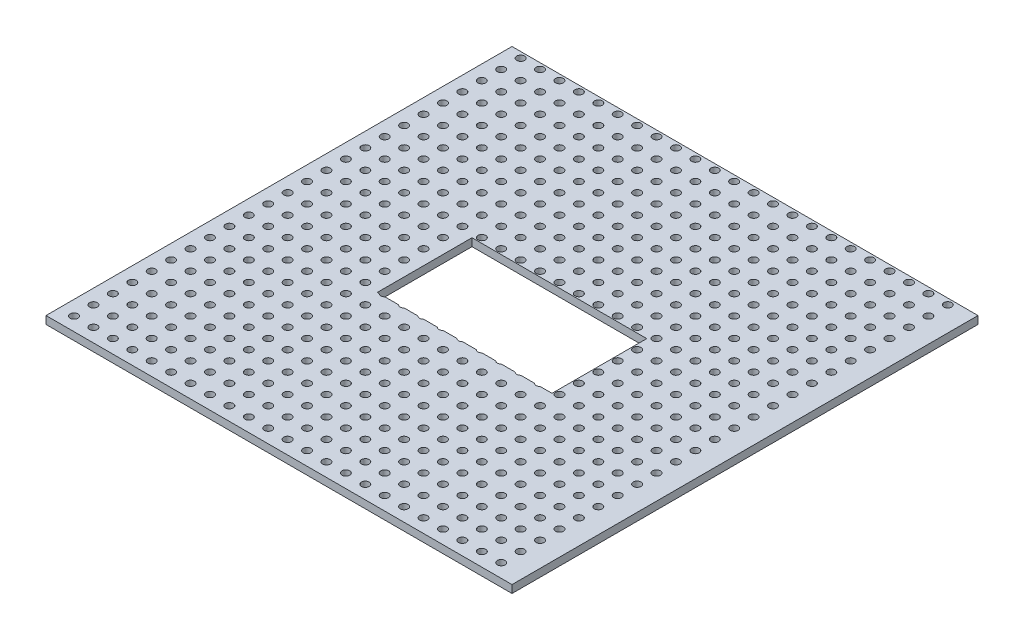
from build123d import *

# Parameters (mm, degrees)
SKETCH1_W           = 60
SKETCH1_H           = 60
SKETCH1_W_2         = 22.5
SKETCH1_H_2         = 12.2
BOSS_EXTRUDE1_DEPTH = 1
SKETCH2_R           = 0.5
CUT_EXTRUDE1_DEPTH  = 2


with BuildPart() as part:
    # Sketch1 → Boss-Extrude1 (new body)
    with BuildSketch(Plane(origin=(0, 0, 0), x_dir=(1, 0, 0), z_dir=(0, 1, 0))):
        with Locations((-12.648237996, 30)):
            Rectangle(SKETCH1_W, SKETCH1_H)
        with Locations((-12.648237996, 30)):
            Rectangle(SKETCH1_W_2, SKETCH1_H_2, mode=Mode.SUBTRACT)
    extrude(amount=BOSS_EXTRUDE1_DEPTH)

    # Sketch2 → Cut-Extrude1 (cut, through all)
    with BuildSketch(Plane(origin=(0, 1, 0), x_dir=(1, 0, 0), z_dir=(0, 1, 0))):
        with Locations((14.218009326, 59.244517789)):
            Circle(SKETCH2_R)
        with Locations((11.718009326, 59.244517789)):
            Circle(SKETCH2_R)
        with Locations((9.218009326, 59.244517789)):
            Circle(SKETCH2_R)
        with Locations((6.718009326, 59.244517789)):
            Circle(SKETCH2_R)
        with Locations((4.218009326, 59.244517789)):
            Circle(SKETCH2_R)
        with Locations((1.718009326, 59.244517789)):
            Circle(SKETCH2_R)
        with Locations((-0.781990674, 59.244517789)):
            Circle(SKETCH2_R)
        with Locations((-3.281990674, 59.244517789)):
            Circle(SKETCH2_R)
        with Locations((-5.781990674, 59.244517789)):
            Circle(SKETCH2_R)
        with Locations((-8.281990674, 59.244517789)):
            Circle(SKETCH2_R)
        with Locations((-10.781990674, 59.244517789)):
            Circle(SKETCH2_R)
        with Locations((-13.281990674, 59.244517789)):
            Circle(SKETCH2_R)
        with Locations((-15.781990674, 59.244517789)):
            Circle(SKETCH2_R)
        with Locations((-18.281990674, 59.244517789)):
            Circle(SKETCH2_R)
        with Locations((-20.781990674, 59.244517789)):
            Circle(SKETCH2_R)
        with Locations((-23.281990674, 59.244517789)):
            Circle(SKETCH2_R)
        with Locations((-25.781990674, 59.244517789)):
            Circle(SKETCH2_R)
        with Locations((-28.281990674, 59.244517789)):
            Circle(SKETCH2_R)
        with Locations((-30.781990674, 59.244517789)):
            Circle(SKETCH2_R)
        with Locations((-33.281990674, 59.244517789)):
            Circle(SKETCH2_R)
        with Locations((-35.781990674, 59.244517789)):
            Circle(SKETCH2_R)
        with Locations((-38.281990674, 59.244517789)):
            Circle(SKETCH2_R)
        with Locations((-40.781990674, 59.244517789)):
            Circle(SKETCH2_R)
        with Locations((-43.281990674, 59.244517789)):
            Circle(SKETCH2_R)
        with Locations((11.718009326, 56.744517789)):
            Circle(SKETCH2_R)
        with Locations((9.218009326, 56.744517789)):
            Circle(SKETCH2_R)
        with Locations((6.718009326, 56.744517789)):
            Circle(SKETCH2_R)
        with Locations((4.218009326, 56.744517789)):
            Circle(SKETCH2_R)
        with Locations((1.718009326, 56.744517789)):
            Circle(SKETCH2_R)
        with Locations((-0.781990674, 56.744517789)):
            Circle(SKETCH2_R)
        with Locations((-3.281990674, 56.744517789)):
            Circle(SKETCH2_R)
        with Locations((-5.781990674, 56.744517789)):
            Circle(SKETCH2_R)
        with Locations((-8.281990674, 56.744517789)):
            Circle(SKETCH2_R)
        with Locations((-10.781990674, 56.744517789)):
            Circle(SKETCH2_R)
        with Locations((-13.281990674, 56.744517789)):
            Circle(SKETCH2_R)
        with Locations((-15.781990674, 56.744517789)):
            Circle(SKETCH2_R)
        with Locations((-18.281990674, 56.744517789)):
            Circle(SKETCH2_R)
        with Locations((-20.781990674, 56.744517789)):
            Circle(SKETCH2_R)
        with Locations((-23.281990674, 56.744517789)):
            Circle(SKETCH2_R)
        with Locations((-25.781990674, 56.744517789)):
            Circle(SKETCH2_R)
        with Locations((-28.281990674, 56.744517789)):
            Circle(SKETCH2_R)
        with Locations((-30.781990674, 56.744517789)):
            Circle(SKETCH2_R)
        with Locations((-33.281990674, 56.744517789)):
            Circle(SKETCH2_R)
        with Locations((-35.781990674, 56.744517789)):
            Circle(SKETCH2_R)
        with Locations((-38.281990674, 56.744517789)):
            Circle(SKETCH2_R)
        with Locations((-40.781990674, 56.744517789)):
            Circle(SKETCH2_R)
        with Locations((-43.281990674, 56.744517789)):
            Circle(SKETCH2_R)
        with Locations((11.718009326, 54.244517789)):
            Circle(SKETCH2_R)
        with Locations((9.218009326, 54.244517789)):
            Circle(SKETCH2_R)
        with Locations((6.718009326, 54.244517789)):
            Circle(SKETCH2_R)
        with Locations((4.218009326, 54.244517789)):
            Circle(SKETCH2_R)
        with Locations((1.718009326, 54.244517789)):
            Circle(SKETCH2_R)
        with Locations((-0.781990674, 54.244517789)):
            Circle(SKETCH2_R)
        with Locations((-3.281990674, 54.244517789)):
            Circle(SKETCH2_R)
        with Locations((-5.781990674, 54.244517789)):
            Circle(SKETCH2_R)
        with Locations((-8.281990674, 54.244517789)):
            Circle(SKETCH2_R)
        with Locations((-10.781990674, 54.244517789)):
            Circle(SKETCH2_R)
        with Locations((-13.281990674, 54.244517789)):
            Circle(SKETCH2_R)
        with Locations((-15.781990674, 54.244517789)):
            Circle(SKETCH2_R)
        with Locations((-18.281990674, 54.244517789)):
            Circle(SKETCH2_R)
        with Locations((-20.781990674, 54.244517789)):
            Circle(SKETCH2_R)
        with Locations((-23.281990674, 54.244517789)):
            Circle(SKETCH2_R)
        with Locations((-25.781990674, 54.244517789)):
            Circle(SKETCH2_R)
        with Locations((-28.281990674, 54.244517789)):
            Circle(SKETCH2_R)
        with Locations((-30.781990674, 54.244517789)):
            Circle(SKETCH2_R)
        with Locations((-33.281990674, 54.244517789)):
            Circle(SKETCH2_R)
        with Locations((-35.781990674, 54.244517789)):
            Circle(SKETCH2_R)
        with Locations((-38.281990674, 54.244517789)):
            Circle(SKETCH2_R)
        with Locations((-40.781990674, 54.244517789)):
            Circle(SKETCH2_R)
        with Locations((-43.281990674, 54.244517789)):
            Circle(SKETCH2_R)
        with Locations((11.718009326, 51.744517789)):
            Circle(SKETCH2_R)
        with Locations((9.218009326, 51.744517789)):
            Circle(SKETCH2_R)
        with Locations((6.718009326, 51.744517789)):
            Circle(SKETCH2_R)
        with Locations((4.218009326, 51.744517789)):
            Circle(SKETCH2_R)
        with Locations((1.718009326, 51.744517789)):
            Circle(SKETCH2_R)
        with Locations((-0.781990674, 51.744517789)):
            Circle(SKETCH2_R)
        with Locations((-3.281990674, 51.744517789)):
            Circle(SKETCH2_R)
        with Locations((-5.781990674, 51.744517789)):
            Circle(SKETCH2_R)
        with Locations((-8.281990674, 51.744517789)):
            Circle(SKETCH2_R)
        with Locations((-10.781990674, 51.744517789)):
            Circle(SKETCH2_R)
        with Locations((-13.281990674, 51.744517789)):
            Circle(SKETCH2_R)
        with Locations((-15.781990674, 51.744517789)):
            Circle(SKETCH2_R)
        with Locations((-18.281990674, 51.744517789)):
            Circle(SKETCH2_R)
        with Locations((-20.781990674, 51.744517789)):
            Circle(SKETCH2_R)
        with Locations((-23.281990674, 51.744517789)):
            Circle(SKETCH2_R)
        with Locations((-25.781990674, 51.744517789)):
            Circle(SKETCH2_R)
        with Locations((-28.281990674, 51.744517789)):
            Circle(SKETCH2_R)
        with Locations((-30.781990674, 51.744517789)):
            Circle(SKETCH2_R)
        with Locations((-33.281990674, 51.744517789)):
            Circle(SKETCH2_R)
        with Locations((-35.781990674, 51.744517789)):
            Circle(SKETCH2_R)
        with Locations((-38.281990674, 51.744517789)):
            Circle(SKETCH2_R)
        with Locations((-40.781990674, 51.744517789)):
            Circle(SKETCH2_R)
        with Locations((-43.281990674, 51.744517789)):
            Circle(SKETCH2_R)
        with Locations((11.718009326, 49.244517789)):
            Circle(SKETCH2_R)
        with Locations((9.218009326, 49.244517789)):
            Circle(SKETCH2_R)
        with Locations((6.718009326, 49.244517789)):
            Circle(SKETCH2_R)
        with Locations((4.218009326, 49.244517789)):
            Circle(SKETCH2_R)
        with Locations((1.718009326, 49.244517789)):
            Circle(SKETCH2_R)
        with Locations((-0.781990674, 49.244517789)):
            Circle(SKETCH2_R)
        with Locations((-3.281990674, 49.244517789)):
            Circle(SKETCH2_R)
        with Locations((-5.781990674, 49.244517789)):
            Circle(SKETCH2_R)
        with Locations((-8.281990674, 49.244517789)):
            Circle(SKETCH2_R)
        with Locations((-10.781990674, 49.244517789)):
            Circle(SKETCH2_R)
        with Locations((-13.281990674, 49.244517789)):
            Circle(SKETCH2_R)
        with Locations((-15.781990674, 49.244517789)):
            Circle(SKETCH2_R)
        with Locations((-18.281990674, 49.244517789)):
            Circle(SKETCH2_R)
        with Locations((-20.781990674, 49.244517789)):
            Circle(SKETCH2_R)
        with Locations((-23.281990674, 49.244517789)):
            Circle(SKETCH2_R)
        with Locations((-25.781990674, 49.244517789)):
            Circle(SKETCH2_R)
        with Locations((-28.281990674, 49.244517789)):
            Circle(SKETCH2_R)
        with Locations((-30.781990674, 49.244517789)):
            Circle(SKETCH2_R)
        with Locations((-33.281990674, 49.244517789)):
            Circle(SKETCH2_R)
        with Locations((-35.781990674, 49.244517789)):
            Circle(SKETCH2_R)
        with Locations((-38.281990674, 49.244517789)):
            Circle(SKETCH2_R)
        with Locations((-40.781990674, 49.244517789)):
            Circle(SKETCH2_R)
        with Locations((-43.281990674, 49.244517789)):
            Circle(SKETCH2_R)
        with Locations((11.718009326, 46.744517789)):
            Circle(SKETCH2_R)
        with Locations((9.218009326, 46.744517789)):
            Circle(SKETCH2_R)
        with Locations((6.718009326, 46.744517789)):
            Circle(SKETCH2_R)
        with Locations((4.218009326, 46.744517789)):
            Circle(SKETCH2_R)
        with Locations((1.718009326, 46.744517789)):
            Circle(SKETCH2_R)
        with Locations((-0.781990674, 46.744517789)):
            Circle(SKETCH2_R)
        with Locations((-3.281990674, 46.744517789)):
            Circle(SKETCH2_R)
        with Locations((-5.781990674, 46.744517789)):
            Circle(SKETCH2_R)
        with Locations((-8.281990674, 46.744517789)):
            Circle(SKETCH2_R)
        with Locations((-10.781990674, 46.744517789)):
            Circle(SKETCH2_R)
        with Locations((-13.281990674, 46.744517789)):
            Circle(SKETCH2_R)
        with Locations((-15.781990674, 46.744517789)):
            Circle(SKETCH2_R)
        with Locations((-18.281990674, 46.744517789)):
            Circle(SKETCH2_R)
        with Locations((-20.781990674, 46.744517789)):
            Circle(SKETCH2_R)
        with Locations((-23.281990674, 46.744517789)):
            Circle(SKETCH2_R)
        with Locations((-25.781990674, 46.744517789)):
            Circle(SKETCH2_R)
        with Locations((-28.281990674, 46.744517789)):
            Circle(SKETCH2_R)
        with Locations((-30.781990674, 46.744517789)):
            Circle(SKETCH2_R)
        with Locations((-33.281990674, 46.744517789)):
            Circle(SKETCH2_R)
        with Locations((-35.781990674, 46.744517789)):
            Circle(SKETCH2_R)
        with Locations((-38.281990674, 46.744517789)):
            Circle(SKETCH2_R)
        with Locations((-40.781990674, 46.744517789)):
            Circle(SKETCH2_R)
        with Locations((-43.281990674, 46.744517789)):
            Circle(SKETCH2_R)
        with Locations((11.718009326, 44.244517789)):
            Circle(SKETCH2_R)
        with Locations((9.218009326, 44.244517789)):
            Circle(SKETCH2_R)
        with Locations((6.718009326, 44.244517789)):
            Circle(SKETCH2_R)
        with Locations((4.218009326, 44.244517789)):
            Circle(SKETCH2_R)
        with Locations((1.718009326, 44.244517789)):
            Circle(SKETCH2_R)
        with Locations((-0.781990674, 44.244517789)):
            Circle(SKETCH2_R)
        with Locations((-3.281990674, 44.244517789)):
            Circle(SKETCH2_R)
        with Locations((-5.781990674, 44.244517789)):
            Circle(SKETCH2_R)
        with Locations((-8.281990674, 44.244517789)):
            Circle(SKETCH2_R)
        with Locations((-10.781990674, 44.244517789)):
            Circle(SKETCH2_R)
        with Locations((-13.281990674, 44.244517789)):
            Circle(SKETCH2_R)
        with Locations((-15.781990674, 44.244517789)):
            Circle(SKETCH2_R)
        with Locations((-18.281990674, 44.244517789)):
            Circle(SKETCH2_R)
        with Locations((-20.781990674, 44.244517789)):
            Circle(SKETCH2_R)
        with Locations((-23.281990674, 44.244517789)):
            Circle(SKETCH2_R)
        with Locations((-25.781990674, 44.244517789)):
            Circle(SKETCH2_R)
        with Locations((-28.281990674, 44.244517789)):
            Circle(SKETCH2_R)
        with Locations((-30.781990674, 44.244517789)):
            Circle(SKETCH2_R)
        with Locations((-33.281990674, 44.244517789)):
            Circle(SKETCH2_R)
        with Locations((-35.781990674, 44.244517789)):
            Circle(SKETCH2_R)
        with Locations((-38.281990674, 44.244517789)):
            Circle(SKETCH2_R)
        with Locations((-40.781990674, 44.244517789)):
            Circle(SKETCH2_R)
        with Locations((-43.281990674, 44.244517789)):
            Circle(SKETCH2_R)
        with Locations((11.718009326, 41.744517789)):
            Circle(SKETCH2_R)
        with Locations((9.218009326, 41.744517789)):
            Circle(SKETCH2_R)
        with Locations((6.718009326, 41.744517789)):
            Circle(SKETCH2_R)
        with Locations((4.218009326, 41.744517789)):
            Circle(SKETCH2_R)
        with Locations((1.718009326, 41.744517789)):
            Circle(SKETCH2_R)
        with Locations((-0.781990674, 41.744517789)):
            Circle(SKETCH2_R)
        with Locations((-3.281990674, 41.744517789)):
            Circle(SKETCH2_R)
        with Locations((-5.781990674, 41.744517789)):
            Circle(SKETCH2_R)
        with Locations((-8.281990674, 41.744517789)):
            Circle(SKETCH2_R)
        with Locations((-10.781990674, 41.744517789)):
            Circle(SKETCH2_R)
        with Locations((-13.281990674, 41.744517789)):
            Circle(SKETCH2_R)
        with Locations((-15.781990674, 41.744517789)):
            Circle(SKETCH2_R)
        with Locations((-18.281990674, 41.744517789)):
            Circle(SKETCH2_R)
        with Locations((-20.781990674, 41.744517789)):
            Circle(SKETCH2_R)
        with Locations((-23.281990674, 41.744517789)):
            Circle(SKETCH2_R)
        with Locations((-25.781990674, 41.744517789)):
            Circle(SKETCH2_R)
        with Locations((-28.281990674, 41.744517789)):
            Circle(SKETCH2_R)
        with Locations((-30.781990674, 41.744517789)):
            Circle(SKETCH2_R)
        with Locations((-33.281990674, 41.744517789)):
            Circle(SKETCH2_R)
        with Locations((-35.781990674, 41.744517789)):
            Circle(SKETCH2_R)
        with Locations((-38.281990674, 41.744517789)):
            Circle(SKETCH2_R)
        with Locations((-40.781990674, 41.744517789)):
            Circle(SKETCH2_R)
        with Locations((-43.281990674, 41.744517789)):
            Circle(SKETCH2_R)
        with Locations((11.718009326, 39.244517789)):
            Circle(SKETCH2_R)
        with Locations((9.218009326, 39.244517789)):
            Circle(SKETCH2_R)
        with Locations((6.718009326, 39.244517789)):
            Circle(SKETCH2_R)
        with Locations((4.218009326, 39.244517789)):
            Circle(SKETCH2_R)
        with Locations((1.718009326, 39.244517789)):
            Circle(SKETCH2_R)
        with Locations((-0.781990674, 39.244517789)):
            Circle(SKETCH2_R)
        with Locations((-3.281990674, 39.244517789)):
            Circle(SKETCH2_R)
        with Locations((-5.781990674, 39.244517789)):
            Circle(SKETCH2_R)
        with Locations((-8.281990674, 39.244517789)):
            Circle(SKETCH2_R)
        with Locations((-10.781990674, 39.244517789)):
            Circle(SKETCH2_R)
        with Locations((-13.281990674, 39.244517789)):
            Circle(SKETCH2_R)
        with Locations((-15.781990674, 39.244517789)):
            Circle(SKETCH2_R)
        with Locations((-18.281990674, 39.244517789)):
            Circle(SKETCH2_R)
        with Locations((-20.781990674, 39.244517789)):
            Circle(SKETCH2_R)
        with Locations((-23.281990674, 39.244517789)):
            Circle(SKETCH2_R)
        with Locations((-25.781990674, 39.244517789)):
            Circle(SKETCH2_R)
        with Locations((-28.281990674, 39.244517789)):
            Circle(SKETCH2_R)
        with Locations((-30.781990674, 39.244517789)):
            Circle(SKETCH2_R)
        with Locations((-33.281990674, 39.244517789)):
            Circle(SKETCH2_R)
        with Locations((-35.781990674, 39.244517789)):
            Circle(SKETCH2_R)
        with Locations((-38.281990674, 39.244517789)):
            Circle(SKETCH2_R)
        with Locations((-40.781990674, 39.244517789)):
            Circle(SKETCH2_R)
        with Locations((-43.281990674, 39.244517789)):
            Circle(SKETCH2_R)
        with Locations((11.718009326, 36.744517789)):
            Circle(SKETCH2_R)
        with Locations((9.218009326, 36.744517789)):
            Circle(SKETCH2_R)
        with Locations((6.718009326, 36.744517789)):
            Circle(SKETCH2_R)
        with Locations((4.218009326, 36.744517789)):
            Circle(SKETCH2_R)
        with Locations((1.718009326, 36.744517789)):
            Circle(SKETCH2_R)
        with Locations((-0.781990674, 36.744517789)):
            Circle(SKETCH2_R)
        with Locations((-3.281990674, 36.744517789)):
            Circle(SKETCH2_R)
        with Locations((-5.781990674, 36.744517789)):
            Circle(SKETCH2_R)
        with Locations((-8.281990674, 36.744517789)):
            Circle(SKETCH2_R)
        with Locations((-10.781990674, 36.744517789)):
            Circle(SKETCH2_R)
        with Locations((-13.281990674, 36.744517789)):
            Circle(SKETCH2_R)
        with Locations((-15.781990674, 36.744517789)):
            Circle(SKETCH2_R)
        with Locations((-18.281990674, 36.744517789)):
            Circle(SKETCH2_R)
        with Locations((-20.781990674, 36.744517789)):
            Circle(SKETCH2_R)
        with Locations((-23.281990674, 36.744517789)):
            Circle(SKETCH2_R)
        with Locations((-25.781990674, 36.744517789)):
            Circle(SKETCH2_R)
        with Locations((-28.281990674, 36.744517789)):
            Circle(SKETCH2_R)
        with Locations((-30.781990674, 36.744517789)):
            Circle(SKETCH2_R)
        with Locations((-33.281990674, 36.744517789)):
            Circle(SKETCH2_R)
        with Locations((-35.781990674, 36.744517789)):
            Circle(SKETCH2_R)
        with Locations((-38.281990674, 36.744517789)):
            Circle(SKETCH2_R)
        with Locations((-40.781990674, 36.744517789)):
            Circle(SKETCH2_R)
        with Locations((-43.281990674, 36.744517789)):
            Circle(SKETCH2_R)
        with Locations((11.718009326, 34.244517789)):
            Circle(SKETCH2_R)
        with Locations((9.218009326, 34.244517789)):
            Circle(SKETCH2_R)
        with Locations((6.718009326, 34.244517789)):
            Circle(SKETCH2_R)
        with Locations((4.218009326, 34.244517789)):
            Circle(SKETCH2_R)
        with Locations((1.718009326, 34.244517789)):
            Circle(SKETCH2_R)
        with Locations((-0.781990674, 34.244517789)):
            Circle(SKETCH2_R)
        with Locations((-3.281990674, 34.244517789)):
            Circle(SKETCH2_R)
        with Locations((-5.781990674, 34.244517789)):
            Circle(SKETCH2_R)
        with Locations((-8.281990674, 34.244517789)):
            Circle(SKETCH2_R)
        with Locations((-10.781990674, 34.244517789)):
            Circle(SKETCH2_R)
        with Locations((-13.281990674, 34.244517789)):
            Circle(SKETCH2_R)
        with Locations((-15.781990674, 34.244517789)):
            Circle(SKETCH2_R)
        with Locations((-18.281990674, 34.244517789)):
            Circle(SKETCH2_R)
        with Locations((-20.781990674, 34.244517789)):
            Circle(SKETCH2_R)
        with Locations((-23.281990674, 34.244517789)):
            Circle(SKETCH2_R)
        with Locations((-25.781990674, 34.244517789)):
            Circle(SKETCH2_R)
        with Locations((-28.281990674, 34.244517789)):
            Circle(SKETCH2_R)
        with Locations((-30.781990674, 34.244517789)):
            Circle(SKETCH2_R)
        with Locations((-33.281990674, 34.244517789)):
            Circle(SKETCH2_R)
        with Locations((-35.781990674, 34.244517789)):
            Circle(SKETCH2_R)
        with Locations((-38.281990674, 34.244517789)):
            Circle(SKETCH2_R)
        with Locations((-40.781990674, 34.244517789)):
            Circle(SKETCH2_R)
        with Locations((-43.281990674, 34.244517789)):
            Circle(SKETCH2_R)
        with Locations((11.718009326, 31.744517789)):
            Circle(SKETCH2_R)
        with Locations((9.218009326, 31.744517789)):
            Circle(SKETCH2_R)
        with Locations((6.718009326, 31.744517789)):
            Circle(SKETCH2_R)
        with Locations((4.218009326, 31.744517789)):
            Circle(SKETCH2_R)
        with Locations((1.718009326, 31.744517789)):
            Circle(SKETCH2_R)
        with Locations((-0.781990674, 31.744517789)):
            Circle(SKETCH2_R)
        with Locations((-3.281990674, 31.744517789)):
            Circle(SKETCH2_R)
        with Locations((-5.781990674, 31.744517789)):
            Circle(SKETCH2_R)
        with Locations((-8.281990674, 31.744517789)):
            Circle(SKETCH2_R)
        with Locations((-10.781990674, 31.744517789)):
            Circle(SKETCH2_R)
        with Locations((-13.281990674, 31.744517789)):
            Circle(SKETCH2_R)
        with Locations((-15.781990674, 31.744517789)):
            Circle(SKETCH2_R)
        with Locations((-18.281990674, 31.744517789)):
            Circle(SKETCH2_R)
        with Locations((-20.781990674, 31.744517789)):
            Circle(SKETCH2_R)
        with Locations((-23.281990674, 31.744517789)):
            Circle(SKETCH2_R)
        with Locations((-25.781990674, 31.744517789)):
            Circle(SKETCH2_R)
        with Locations((-28.281990674, 31.744517789)):
            Circle(SKETCH2_R)
        with Locations((-30.781990674, 31.744517789)):
            Circle(SKETCH2_R)
        with Locations((-33.281990674, 31.744517789)):
            Circle(SKETCH2_R)
        with Locations((-35.781990674, 31.744517789)):
            Circle(SKETCH2_R)
        with Locations((-38.281990674, 31.744517789)):
            Circle(SKETCH2_R)
        with Locations((-40.781990674, 31.744517789)):
            Circle(SKETCH2_R)
        with Locations((-43.281990674, 31.744517789)):
            Circle(SKETCH2_R)
        with Locations((11.718009326, 29.244517789)):
            Circle(SKETCH2_R)
        with Locations((9.218009326, 29.244517789)):
            Circle(SKETCH2_R)
        with Locations((6.718009326, 29.244517789)):
            Circle(SKETCH2_R)
        with Locations((4.218009326, 29.244517789)):
            Circle(SKETCH2_R)
        with Locations((1.718009326, 29.244517789)):
            Circle(SKETCH2_R)
        with Locations((-0.781990674, 29.244517789)):
            Circle(SKETCH2_R)
        with Locations((-3.281990674, 29.244517789)):
            Circle(SKETCH2_R)
        with Locations((-5.781990674, 29.244517789)):
            Circle(SKETCH2_R)
        with Locations((-8.281990674, 29.244517789)):
            Circle(SKETCH2_R)
        with Locations((-10.781990674, 29.244517789)):
            Circle(SKETCH2_R)
        with Locations((-13.281990674, 29.244517789)):
            Circle(SKETCH2_R)
        with Locations((-15.781990674, 29.244517789)):
            Circle(SKETCH2_R)
        with Locations((-18.281990674, 29.244517789)):
            Circle(SKETCH2_R)
        with Locations((-20.781990674, 29.244517789)):
            Circle(SKETCH2_R)
        with Locations((-23.281990674, 29.244517789)):
            Circle(SKETCH2_R)
        with Locations((-25.781990674, 29.244517789)):
            Circle(SKETCH2_R)
        with Locations((-28.281990674, 29.244517789)):
            Circle(SKETCH2_R)
        with Locations((-30.781990674, 29.244517789)):
            Circle(SKETCH2_R)
        with Locations((-33.281990674, 29.244517789)):
            Circle(SKETCH2_R)
        with Locations((-35.781990674, 29.244517789)):
            Circle(SKETCH2_R)
        with Locations((-38.281990674, 29.244517789)):
            Circle(SKETCH2_R)
        with Locations((-40.781990674, 29.244517789)):
            Circle(SKETCH2_R)
        with Locations((-43.281990674, 29.244517789)):
            Circle(SKETCH2_R)
        with Locations((11.718009326, 26.744517789)):
            Circle(SKETCH2_R)
        with Locations((9.218009326, 26.744517789)):
            Circle(SKETCH2_R)
        with Locations((6.718009326, 26.744517789)):
            Circle(SKETCH2_R)
        with Locations((4.218009326, 26.744517789)):
            Circle(SKETCH2_R)
        with Locations((1.718009326, 26.744517789)):
            Circle(SKETCH2_R)
        with Locations((-0.781990674, 26.744517789)):
            Circle(SKETCH2_R)
        with Locations((-3.281990674, 26.744517789)):
            Circle(SKETCH2_R)
        with Locations((-5.781990674, 26.744517789)):
            Circle(SKETCH2_R)
        with Locations((-8.281990674, 26.744517789)):
            Circle(SKETCH2_R)
        with Locations((-10.781990674, 26.744517789)):
            Circle(SKETCH2_R)
        with Locations((-13.281990674, 26.744517789)):
            Circle(SKETCH2_R)
        with Locations((-15.781990674, 26.744517789)):
            Circle(SKETCH2_R)
        with Locations((-18.281990674, 26.744517789)):
            Circle(SKETCH2_R)
        with Locations((-20.781990674, 26.744517789)):
            Circle(SKETCH2_R)
        with Locations((-23.281990674, 26.744517789)):
            Circle(SKETCH2_R)
        with Locations((-25.781990674, 26.744517789)):
            Circle(SKETCH2_R)
        with Locations((-28.281990674, 26.744517789)):
            Circle(SKETCH2_R)
        with Locations((-30.781990674, 26.744517789)):
            Circle(SKETCH2_R)
        with Locations((-33.281990674, 26.744517789)):
            Circle(SKETCH2_R)
        with Locations((-35.781990674, 26.744517789)):
            Circle(SKETCH2_R)
        with Locations((-38.281990674, 26.744517789)):
            Circle(SKETCH2_R)
        with Locations((-40.781990674, 26.744517789)):
            Circle(SKETCH2_R)
        with Locations((-43.281990674, 26.744517789)):
            Circle(SKETCH2_R)
        with Locations((11.718009326, 24.244517789)):
            Circle(SKETCH2_R)
        with Locations((9.218009326, 24.244517789)):
            Circle(SKETCH2_R)
        with Locations((6.718009326, 24.244517789)):
            Circle(SKETCH2_R)
        with Locations((4.218009326, 24.244517789)):
            Circle(SKETCH2_R)
        with Locations((1.718009326, 24.244517789)):
            Circle(SKETCH2_R)
        with Locations((-0.781990674, 24.244517789)):
            Circle(SKETCH2_R)
        with Locations((-3.281990674, 24.244517789)):
            Circle(SKETCH2_R)
        with Locations((-5.781990674, 24.244517789)):
            Circle(SKETCH2_R)
        with Locations((-8.281990674, 24.244517789)):
            Circle(SKETCH2_R)
        with Locations((-10.781990674, 24.244517789)):
            Circle(SKETCH2_R)
        with Locations((-13.281990674, 24.244517789)):
            Circle(SKETCH2_R)
        with Locations((-15.781990674, 24.244517789)):
            Circle(SKETCH2_R)
        with Locations((-18.281990674, 24.244517789)):
            Circle(SKETCH2_R)
        with Locations((-20.781990674, 24.244517789)):
            Circle(SKETCH2_R)
        with Locations((-23.281990674, 24.244517789)):
            Circle(SKETCH2_R)
        with Locations((-25.781990674, 24.244517789)):
            Circle(SKETCH2_R)
        with Locations((-28.281990674, 24.244517789)):
            Circle(SKETCH2_R)
        with Locations((-30.781990674, 24.244517789)):
            Circle(SKETCH2_R)
        with Locations((-33.281990674, 24.244517789)):
            Circle(SKETCH2_R)
        with Locations((-35.781990674, 24.244517789)):
            Circle(SKETCH2_R)
        with Locations((-38.281990674, 24.244517789)):
            Circle(SKETCH2_R)
        with Locations((-40.781990674, 24.244517789)):
            Circle(SKETCH2_R)
        with Locations((-43.281990674, 24.244517789)):
            Circle(SKETCH2_R)
        with Locations((11.718009326, 21.744517789)):
            Circle(SKETCH2_R)
        with Locations((9.218009326, 21.744517789)):
            Circle(SKETCH2_R)
        with Locations((6.718009326, 21.744517789)):
            Circle(SKETCH2_R)
        with Locations((4.218009326, 21.744517789)):
            Circle(SKETCH2_R)
        with Locations((1.718009326, 21.744517789)):
            Circle(SKETCH2_R)
        with Locations((-0.781990674, 21.744517789)):
            Circle(SKETCH2_R)
        with Locations((-3.281990674, 21.744517789)):
            Circle(SKETCH2_R)
        with Locations((-5.781990674, 21.744517789)):
            Circle(SKETCH2_R)
        with Locations((-8.281990674, 21.744517789)):
            Circle(SKETCH2_R)
        with Locations((-10.781990674, 21.744517789)):
            Circle(SKETCH2_R)
        with Locations((-13.281990674, 21.744517789)):
            Circle(SKETCH2_R)
        with Locations((-15.781990674, 21.744517789)):
            Circle(SKETCH2_R)
        with Locations((-18.281990674, 21.744517789)):
            Circle(SKETCH2_R)
        with Locations((-20.781990674, 21.744517789)):
            Circle(SKETCH2_R)
        with Locations((-23.281990674, 21.744517789)):
            Circle(SKETCH2_R)
        with Locations((-25.781990674, 21.744517789)):
            Circle(SKETCH2_R)
        with Locations((-28.281990674, 21.744517789)):
            Circle(SKETCH2_R)
        with Locations((-30.781990674, 21.744517789)):
            Circle(SKETCH2_R)
        with Locations((-33.281990674, 21.744517789)):
            Circle(SKETCH2_R)
        with Locations((-35.781990674, 21.744517789)):
            Circle(SKETCH2_R)
        with Locations((-38.281990674, 21.744517789)):
            Circle(SKETCH2_R)
        with Locations((-40.781990674, 21.744517789)):
            Circle(SKETCH2_R)
        with Locations((-43.281990674, 21.744517789)):
            Circle(SKETCH2_R)
        with Locations((11.718009326, 19.244517789)):
            Circle(SKETCH2_R)
        with Locations((9.218009326, 19.244517789)):
            Circle(SKETCH2_R)
        with Locations((6.718009326, 19.244517789)):
            Circle(SKETCH2_R)
        with Locations((4.218009326, 19.244517789)):
            Circle(SKETCH2_R)
        with Locations((1.718009326, 19.244517789)):
            Circle(SKETCH2_R)
        with Locations((-0.781990674, 19.244517789)):
            Circle(SKETCH2_R)
        with Locations((-3.281990674, 19.244517789)):
            Circle(SKETCH2_R)
        with Locations((-5.781990674, 19.244517789)):
            Circle(SKETCH2_R)
        with Locations((-8.281990674, 19.244517789)):
            Circle(SKETCH2_R)
        with Locations((-10.781990674, 19.244517789)):
            Circle(SKETCH2_R)
        with Locations((-13.281990674, 19.244517789)):
            Circle(SKETCH2_R)
        with Locations((-15.781990674, 19.244517789)):
            Circle(SKETCH2_R)
        with Locations((-18.281990674, 19.244517789)):
            Circle(SKETCH2_R)
        with Locations((-20.781990674, 19.244517789)):
            Circle(SKETCH2_R)
        with Locations((-23.281990674, 19.244517789)):
            Circle(SKETCH2_R)
        with Locations((-25.781990674, 19.244517789)):
            Circle(SKETCH2_R)
        with Locations((-28.281990674, 19.244517789)):
            Circle(SKETCH2_R)
        with Locations((-30.781990674, 19.244517789)):
            Circle(SKETCH2_R)
        with Locations((-33.281990674, 19.244517789)):
            Circle(SKETCH2_R)
        with Locations((-35.781990674, 19.244517789)):
            Circle(SKETCH2_R)
        with Locations((-38.281990674, 19.244517789)):
            Circle(SKETCH2_R)
        with Locations((-40.781990674, 19.244517789)):
            Circle(SKETCH2_R)
        with Locations((-43.281990674, 19.244517789)):
            Circle(SKETCH2_R)
        with Locations((11.718009326, 16.744517789)):
            Circle(SKETCH2_R)
        with Locations((9.218009326, 16.744517789)):
            Circle(SKETCH2_R)
        with Locations((6.718009326, 16.744517789)):
            Circle(SKETCH2_R)
        with Locations((4.218009326, 16.744517789)):
            Circle(SKETCH2_R)
        with Locations((1.718009326, 16.744517789)):
            Circle(SKETCH2_R)
        with Locations((-0.781990674, 16.744517789)):
            Circle(SKETCH2_R)
        with Locations((-3.281990674, 16.744517789)):
            Circle(SKETCH2_R)
        with Locations((-5.781990674, 16.744517789)):
            Circle(SKETCH2_R)
        with Locations((-8.281990674, 16.744517789)):
            Circle(SKETCH2_R)
        with Locations((-10.781990674, 16.744517789)):
            Circle(SKETCH2_R)
        with Locations((-13.281990674, 16.744517789)):
            Circle(SKETCH2_R)
        with Locations((-15.781990674, 16.744517789)):
            Circle(SKETCH2_R)
        with Locations((-18.281990674, 16.744517789)):
            Circle(SKETCH2_R)
        with Locations((-20.781990674, 16.744517789)):
            Circle(SKETCH2_R)
        with Locations((-23.281990674, 16.744517789)):
            Circle(SKETCH2_R)
        with Locations((-25.781990674, 16.744517789)):
            Circle(SKETCH2_R)
        with Locations((-28.281990674, 16.744517789)):
            Circle(SKETCH2_R)
        with Locations((-30.781990674, 16.744517789)):
            Circle(SKETCH2_R)
        with Locations((-33.281990674, 16.744517789)):
            Circle(SKETCH2_R)
        with Locations((-35.781990674, 16.744517789)):
            Circle(SKETCH2_R)
        with Locations((-38.281990674, 16.744517789)):
            Circle(SKETCH2_R)
        with Locations((-40.781990674, 16.744517789)):
            Circle(SKETCH2_R)
        with Locations((-43.281990674, 16.744517789)):
            Circle(SKETCH2_R)
        with Locations((11.718009326, 14.244517789)):
            Circle(SKETCH2_R)
        with Locations((9.218009326, 14.244517789)):
            Circle(SKETCH2_R)
        with Locations((6.718009326, 14.244517789)):
            Circle(SKETCH2_R)
        with Locations((4.218009326, 14.244517789)):
            Circle(SKETCH2_R)
        with Locations((1.718009326, 14.244517789)):
            Circle(SKETCH2_R)
        with Locations((-0.781990674, 14.244517789)):
            Circle(SKETCH2_R)
        with Locations((-3.281990674, 14.244517789)):
            Circle(SKETCH2_R)
        with Locations((-5.781990674, 14.244517789)):
            Circle(SKETCH2_R)
        with Locations((-8.281990674, 14.244517789)):
            Circle(SKETCH2_R)
        with Locations((-10.781990674, 14.244517789)):
            Circle(SKETCH2_R)
        with Locations((-13.281990674, 14.244517789)):
            Circle(SKETCH2_R)
        with Locations((-15.781990674, 14.244517789)):
            Circle(SKETCH2_R)
        with Locations((-18.281990674, 14.244517789)):
            Circle(SKETCH2_R)
        with Locations((-20.781990674, 14.244517789)):
            Circle(SKETCH2_R)
        with Locations((-23.281990674, 14.244517789)):
            Circle(SKETCH2_R)
        with Locations((-25.781990674, 14.244517789)):
            Circle(SKETCH2_R)
        with Locations((-28.281990674, 14.244517789)):
            Circle(SKETCH2_R)
        with Locations((-30.781990674, 14.244517789)):
            Circle(SKETCH2_R)
        with Locations((-33.281990674, 14.244517789)):
            Circle(SKETCH2_R)
        with Locations((-35.781990674, 14.244517789)):
            Circle(SKETCH2_R)
        with Locations((-38.281990674, 14.244517789)):
            Circle(SKETCH2_R)
        with Locations((-40.781990674, 14.244517789)):
            Circle(SKETCH2_R)
        with Locations((-43.281990674, 14.244517789)):
            Circle(SKETCH2_R)
        with Locations((11.718009326, 11.744517789)):
            Circle(SKETCH2_R)
        with Locations((9.218009326, 11.744517789)):
            Circle(SKETCH2_R)
        with Locations((6.718009326, 11.744517789)):
            Circle(SKETCH2_R)
        with Locations((4.218009326, 11.744517789)):
            Circle(SKETCH2_R)
        with Locations((1.718009326, 11.744517789)):
            Circle(SKETCH2_R)
        with Locations((-0.781990674, 11.744517789)):
            Circle(SKETCH2_R)
        with Locations((-3.281990674, 11.744517789)):
            Circle(SKETCH2_R)
        with Locations((-5.781990674, 11.744517789)):
            Circle(SKETCH2_R)
        with Locations((-8.281990674, 11.744517789)):
            Circle(SKETCH2_R)
        with Locations((-10.781990674, 11.744517789)):
            Circle(SKETCH2_R)
        with Locations((-13.281990674, 11.744517789)):
            Circle(SKETCH2_R)
        with Locations((-15.781990674, 11.744517789)):
            Circle(SKETCH2_R)
        with Locations((-18.281990674, 11.744517789)):
            Circle(SKETCH2_R)
        with Locations((-20.781990674, 11.744517789)):
            Circle(SKETCH2_R)
        with Locations((-23.281990674, 11.744517789)):
            Circle(SKETCH2_R)
        with Locations((-25.781990674, 11.744517789)):
            Circle(SKETCH2_R)
        with Locations((-28.281990674, 11.744517789)):
            Circle(SKETCH2_R)
        with Locations((-30.781990674, 11.744517789)):
            Circle(SKETCH2_R)
        with Locations((-33.281990674, 11.744517789)):
            Circle(SKETCH2_R)
        with Locations((-35.781990674, 11.744517789)):
            Circle(SKETCH2_R)
        with Locations((-38.281990674, 11.744517789)):
            Circle(SKETCH2_R)
        with Locations((-40.781990674, 11.744517789)):
            Circle(SKETCH2_R)
        with Locations((-43.281990674, 11.744517789)):
            Circle(SKETCH2_R)
        with Locations((11.718009326, 9.244517789)):
            Circle(SKETCH2_R)
        with Locations((9.218009326, 9.244517789)):
            Circle(SKETCH2_R)
        with Locations((6.718009326, 9.244517789)):
            Circle(SKETCH2_R)
        with Locations((4.218009326, 9.244517789)):
            Circle(SKETCH2_R)
        with Locations((1.718009326, 9.244517789)):
            Circle(SKETCH2_R)
        with Locations((-0.781990674, 9.244517789)):
            Circle(SKETCH2_R)
        with Locations((-3.281990674, 9.244517789)):
            Circle(SKETCH2_R)
        with Locations((-5.781990674, 9.244517789)):
            Circle(SKETCH2_R)
        with Locations((-8.281990674, 9.244517789)):
            Circle(SKETCH2_R)
        with Locations((-10.781990674, 9.244517789)):
            Circle(SKETCH2_R)
        with Locations((-13.281990674, 9.244517789)):
            Circle(SKETCH2_R)
        with Locations((-15.781990674, 9.244517789)):
            Circle(SKETCH2_R)
        with Locations((-18.281990674, 9.244517789)):
            Circle(SKETCH2_R)
        with Locations((-20.781990674, 9.244517789)):
            Circle(SKETCH2_R)
        with Locations((-23.281990674, 9.244517789)):
            Circle(SKETCH2_R)
        with Locations((-25.781990674, 9.244517789)):
            Circle(SKETCH2_R)
        with Locations((-28.281990674, 9.244517789)):
            Circle(SKETCH2_R)
        with Locations((-30.781990674, 9.244517789)):
            Circle(SKETCH2_R)
        with Locations((-33.281990674, 9.244517789)):
            Circle(SKETCH2_R)
        with Locations((-35.781990674, 9.244517789)):
            Circle(SKETCH2_R)
        with Locations((-38.281990674, 9.244517789)):
            Circle(SKETCH2_R)
        with Locations((-40.781990674, 9.244517789)):
            Circle(SKETCH2_R)
        with Locations((-43.281990674, 9.244517789)):
            Circle(SKETCH2_R)
        with Locations((11.718009326, 6.744517789)):
            Circle(SKETCH2_R)
        with Locations((9.218009326, 6.744517789)):
            Circle(SKETCH2_R)
        with Locations((6.718009326, 6.744517789)):
            Circle(SKETCH2_R)
        with Locations((4.218009326, 6.744517789)):
            Circle(SKETCH2_R)
        with Locations((1.718009326, 6.744517789)):
            Circle(SKETCH2_R)
        with Locations((-0.781990674, 6.744517789)):
            Circle(SKETCH2_R)
        with Locations((-3.281990674, 6.744517789)):
            Circle(SKETCH2_R)
        with Locations((-5.781990674, 6.744517789)):
            Circle(SKETCH2_R)
        with Locations((-8.281990674, 6.744517789)):
            Circle(SKETCH2_R)
        with Locations((-10.781990674, 6.744517789)):
            Circle(SKETCH2_R)
        with Locations((-13.281990674, 6.744517789)):
            Circle(SKETCH2_R)
        with Locations((-15.781990674, 6.744517789)):
            Circle(SKETCH2_R)
        with Locations((-18.281990674, 6.744517789)):
            Circle(SKETCH2_R)
        with Locations((-20.781990674, 6.744517789)):
            Circle(SKETCH2_R)
        with Locations((-23.281990674, 6.744517789)):
            Circle(SKETCH2_R)
        with Locations((-25.781990674, 6.744517789)):
            Circle(SKETCH2_R)
        with Locations((-28.281990674, 6.744517789)):
            Circle(SKETCH2_R)
        with Locations((-30.781990674, 6.744517789)):
            Circle(SKETCH2_R)
        with Locations((-33.281990674, 6.744517789)):
            Circle(SKETCH2_R)
        with Locations((-35.781990674, 6.744517789)):
            Circle(SKETCH2_R)
        with Locations((-38.281990674, 6.744517789)):
            Circle(SKETCH2_R)
        with Locations((-40.781990674, 6.744517789)):
            Circle(SKETCH2_R)
        with Locations((-43.281990674, 6.744517789)):
            Circle(SKETCH2_R)
        with Locations((11.718009326, 4.244517789)):
            Circle(SKETCH2_R)
        with Locations((9.218009326, 4.244517789)):
            Circle(SKETCH2_R)
        with Locations((6.718009326, 4.244517789)):
            Circle(SKETCH2_R)
        with Locations((4.218009326, 4.244517789)):
            Circle(SKETCH2_R)
        with Locations((1.718009326, 4.244517789)):
            Circle(SKETCH2_R)
        with Locations((-0.781990674, 4.244517789)):
            Circle(SKETCH2_R)
        with Locations((-3.281990674, 4.244517789)):
            Circle(SKETCH2_R)
        with Locations((-5.781990674, 4.244517789)):
            Circle(SKETCH2_R)
        with Locations((-8.281990674, 4.244517789)):
            Circle(SKETCH2_R)
        with Locations((-10.781990674, 4.244517789)):
            Circle(SKETCH2_R)
        with Locations((-13.281990674, 4.244517789)):
            Circle(SKETCH2_R)
        with Locations((-15.781990674, 4.244517789)):
            Circle(SKETCH2_R)
        with Locations((-18.281990674, 4.244517789)):
            Circle(SKETCH2_R)
        with Locations((-20.781990674, 4.244517789)):
            Circle(SKETCH2_R)
        with Locations((-23.281990674, 4.244517789)):
            Circle(SKETCH2_R)
        with Locations((-25.781990674, 4.244517789)):
            Circle(SKETCH2_R)
        with Locations((-28.281990674, 4.244517789)):
            Circle(SKETCH2_R)
        with Locations((-30.781990674, 4.244517789)):
            Circle(SKETCH2_R)
        with Locations((-33.281990674, 4.244517789)):
            Circle(SKETCH2_R)
        with Locations((-35.781990674, 4.244517789)):
            Circle(SKETCH2_R)
        with Locations((-38.281990674, 4.244517789)):
            Circle(SKETCH2_R)
        with Locations((-40.781990674, 4.244517789)):
            Circle(SKETCH2_R)
        with Locations((-43.281990674, 4.244517789)):
            Circle(SKETCH2_R)
        with Locations((11.718009326, 1.744517789)):
            Circle(SKETCH2_R)
        with Locations((9.218009326, 1.744517789)):
            Circle(SKETCH2_R)
        with Locations((6.718009326, 1.744517789)):
            Circle(SKETCH2_R)
        with Locations((4.218009326, 1.744517789)):
            Circle(SKETCH2_R)
        with Locations((1.718009326, 1.744517789)):
            Circle(SKETCH2_R)
        with Locations((-0.781990674, 1.744517789)):
            Circle(SKETCH2_R)
        with Locations((-3.281990674, 1.744517789)):
            Circle(SKETCH2_R)
        with Locations((-5.781990674, 1.744517789)):
            Circle(SKETCH2_R)
        with Locations((-8.281990674, 1.744517789)):
            Circle(SKETCH2_R)
        with Locations((-10.781990674, 1.744517789)):
            Circle(SKETCH2_R)
        with Locations((-13.281990674, 1.744517789)):
            Circle(SKETCH2_R)
        with Locations((-15.781990674, 1.744517789)):
            Circle(SKETCH2_R)
        with Locations((-18.281990674, 1.744517789)):
            Circle(SKETCH2_R)
        with Locations((-20.781990674, 1.744517789)):
            Circle(SKETCH2_R)
        with Locations((-23.281990674, 1.744517789)):
            Circle(SKETCH2_R)
        with Locations((-25.781990674, 1.744517789)):
            Circle(SKETCH2_R)
        with Locations((-28.281990674, 1.744517789)):
            Circle(SKETCH2_R)
        with Locations((-30.781990674, 1.744517789)):
            Circle(SKETCH2_R)
        with Locations((-33.281990674, 1.744517789)):
            Circle(SKETCH2_R)
        with Locations((-35.781990674, 1.744517789)):
            Circle(SKETCH2_R)
        with Locations((-38.281990674, 1.744517789)):
            Circle(SKETCH2_R)
        with Locations((-40.781990674, 1.744517789)):
            Circle(SKETCH2_R)
        with Locations((-43.281990674, 1.744517789)):
            Circle(SKETCH2_R)
        with Locations((14.218009326, 56.744517789)):
            Circle(SKETCH2_R)
        with Locations((14.218009326, 54.244517789)):
            Circle(SKETCH2_R)
        with Locations((14.218009326, 51.744517789)):
            Circle(SKETCH2_R)
        with Locations((14.218009326, 49.244517789)):
            Circle(SKETCH2_R)
        with Locations((14.218009326, 46.744517789)):
            Circle(SKETCH2_R)
        with Locations((14.218009326, 44.244517789)):
            Circle(SKETCH2_R)
        with Locations((14.218009326, 41.744517789)):
            Circle(SKETCH2_R)
        with Locations((14.218009326, 39.244517789)):
            Circle(SKETCH2_R)
        with Locations((14.218009326, 36.744517789)):
            Circle(SKETCH2_R)
        with Locations((14.218009326, 34.244517789)):
            Circle(SKETCH2_R)
        with Locations((14.218009326, 31.744517789)):
            Circle(SKETCH2_R)
        with Locations((14.218009326, 29.244517789)):
            Circle(SKETCH2_R)
        with Locations((14.218009326, 26.744517789)):
            Circle(SKETCH2_R)
        with Locations((14.218009326, 24.244517789)):
            Circle(SKETCH2_R)
        with Locations((14.218009326, 21.744517789)):
            Circle(SKETCH2_R)
        with Locations((14.218009326, 19.244517789)):
            Circle(SKETCH2_R)
        with Locations((14.218009326, 16.744517789)):
            Circle(SKETCH2_R)
        with Locations((14.218009326, 14.244517789)):
            Circle(SKETCH2_R)
        with Locations((14.218009326, 11.744517789)):
            Circle(SKETCH2_R)
        with Locations((14.218009326, 9.244517789)):
            Circle(SKETCH2_R)
        with Locations((14.218009326, 6.744517789)):
            Circle(SKETCH2_R)
        with Locations((14.218009326, 4.244517789)):
            Circle(SKETCH2_R)
        with Locations((14.218009326, 1.744517789)):
            Circle(SKETCH2_R)
    extrude(amount=-CUT_EXTRUDE1_DEPTH, mode=Mode.SUBTRACT)


solid = part.part
